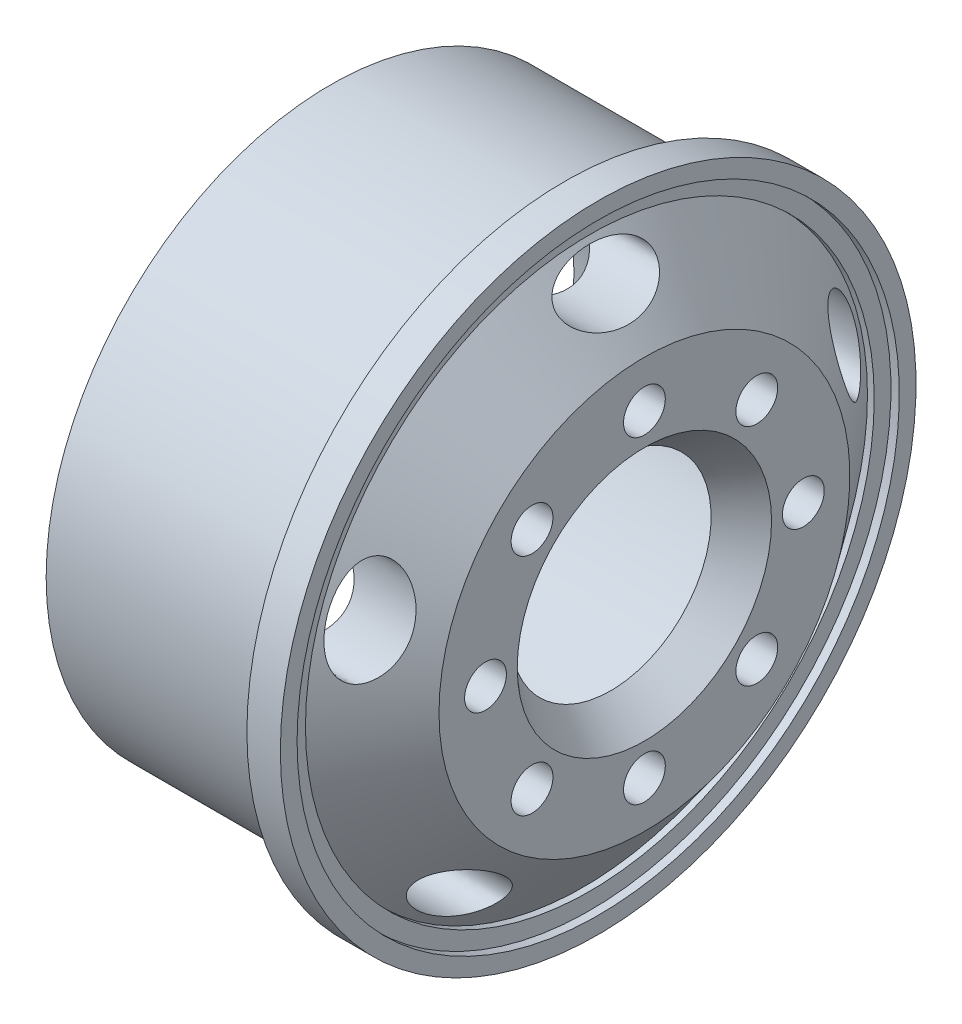
from build123d import *

# Parameters (mm, degrees)
SKETCH2_R          = 1.25
CUT_EXTRUDE1_DEPTH = 33.77256177
CUT_EXTRUDE2_REACH = 34.773
SKETCH3_RX         = 3
SKETCH3_RY         = 1.5


with BuildPart() as part:
    # Sketch1 → Revolve1 (revolve)
    with BuildSketch(Plane(origin=(0, 0, 0), x_dir=(1, 0, 0), z_dir=(0, 1, 0)), mode=Mode.PRIVATE) as revolve1_sk:
        Polygon((2.943128086, 14.55), (6.936305636, 11.540924884), (6.936305636, 6), (8.9490561, 7.601756853), (8.9490561, 12.280236789), (5.283321269, 17), (5.686305636, 17), (5.686305636, 18), (6.186305636, 18), (6.186305636, 19), (5.686305636, 19), (4.186305636, 19), (4.186305636, 17), (-9.813694364, 17), (-9.813694364, 14.55), align=None)
    revolve(revolve1_sk.sketch.rotate(Axis((-37.278866169, 0, 0), (1, 0, 0)), 180), axis=Axis((-37.278866169, 0, 0), (1, 0, 0)))

    # Sketch2 → Cut-Extrude1 (cut, through all)
    with BuildSketch(Plane(origin=(8.9490561, 0, 0), x_dir=(0, 0, -1), z_dir=(1, 0, 0))):
        with Locations((0, 9.5)):
            Circle(SKETCH2_R)
        with Locations((6.717514421, 6.717514421)):
            Circle(SKETCH2_R)
        with Locations((9.5, 0)):
            Circle(SKETCH2_R)
        with Locations((6.717514421, -6.717514421)):
            Circle(SKETCH2_R)
        with Locations((0, -9.5)):
            Circle(SKETCH2_R)
        with Locations((-6.717514421, -6.717514421)):
            Circle(SKETCH2_R)
        with Locations((-9.5, 0)):
            Circle(SKETCH2_R)
        with Locations((-6.717514421, 6.717514421)):
            Circle(SKETCH2_R)
    extrude(amount=-CUT_EXTRUDE1_DEPTH, mode=Mode.SUBTRACT)

    # Cut-Extrude2: up to this cone (the profile starts outside it)
    cut_extrude2_end = Plane(origin=(8.949056, 0, 0), z_dir=(-1, 0, 0)).offset(-13.30257324) * Cone(1e-06, 44.158103766, 58.599781936, align=(Align.CENTER, Align.CENTER, Align.MIN), mode=Mode.PRIVATE)
    # Sketch3 → Cut-Extrude2 (cut, up to the surface)
    with BuildSketch(Plane(origin=(8.9490561, 0, 0), x_dir=(0, 0, -1), z_dir=(1, 0, 0)), mode=Mode.PRIVATE) as cut_extrude2_sk1:
        with Locations((0, 15)):
            Ellipse(SKETCH3_RX, SKETCH3_RY)
    cut_extrude2_tool1 = extrude(cut_extrude2_sk1.sketch, amount=-CUT_EXTRUDE2_REACH, mode=Mode.PRIVATE) - cut_extrude2_end
    add(cut_extrude2_tool1.solids().sort_by_distance((8.949056, 15, 0))[0], mode=Mode.SUBTRACT)
    # Sketch3 → Cut-Extrude2 (cut, up to the surface)
    with BuildSketch(Plane(origin=(8.9490561, 0, 0), x_dir=(0, 0, -1), z_dir=(1, 0, 0)), mode=Mode.PRIVATE) as cut_extrude2_sk2:
        with Locations(Location((14.265847744, 4.635254916), (0, 0, -72))):
            Ellipse(SKETCH3_RX, SKETCH3_RY)
    cut_extrude2_tool2 = extrude(cut_extrude2_sk2.sketch, amount=-CUT_EXTRUDE2_REACH, mode=Mode.PRIVATE) - cut_extrude2_end
    add(cut_extrude2_tool2.solids().sort_by_distance((8.949056, 4.635255, -14.265848))[0], mode=Mode.SUBTRACT)
    # Sketch3 → Cut-Extrude2 (cut, up to the surface)
    with BuildSketch(Plane(origin=(8.9490561, 0, 0), x_dir=(0, 0, -1), z_dir=(1, 0, 0)), mode=Mode.PRIVATE) as cut_extrude2_sk3:
        with Locations(Location((8.816778784, -12.135254916), (0, 0, -144))):
            Ellipse(SKETCH3_RX, SKETCH3_RY)
    cut_extrude2_tool3 = extrude(cut_extrude2_sk3.sketch, amount=-CUT_EXTRUDE2_REACH, mode=Mode.PRIVATE) - cut_extrude2_end
    add(cut_extrude2_tool3.solids().sort_by_distance((8.949056, -12.135255, -8.816779))[0], mode=Mode.SUBTRACT)
    # Sketch3 → Cut-Extrude2 (cut, up to the surface)
    with BuildSketch(Plane(origin=(8.9490561, 0, 0), x_dir=(0, 0, -1), z_dir=(1, 0, 0)), mode=Mode.PRIVATE) as cut_extrude2_sk4:
        with Locations(Location((-8.816778784, -12.135254916), (0, 0, 144))):
            Ellipse(SKETCH3_RX, SKETCH3_RY)
    cut_extrude2_tool4 = extrude(cut_extrude2_sk4.sketch, amount=-CUT_EXTRUDE2_REACH, mode=Mode.PRIVATE) - cut_extrude2_end
    add(cut_extrude2_tool4.solids().sort_by_distance((8.949056, -12.135255, 8.816779))[0], mode=Mode.SUBTRACT)
    # Sketch3 → Cut-Extrude2 (cut, up to the surface)
    with BuildSketch(Plane(origin=(8.9490561, 0, 0), x_dir=(0, 0, -1), z_dir=(1, 0, 0)), mode=Mode.PRIVATE) as cut_extrude2_sk5:
        with Locations(Location((-14.265847744, 4.635254916), (0, 0, 72))):
            Ellipse(SKETCH3_RX, SKETCH3_RY)
    cut_extrude2_tool5 = extrude(cut_extrude2_sk5.sketch, amount=-CUT_EXTRUDE2_REACH, mode=Mode.PRIVATE) - cut_extrude2_end
    add(cut_extrude2_tool5.solids().sort_by_distance((8.949056, 4.635255, 14.265848))[0], mode=Mode.SUBTRACT)


solid = part.part
